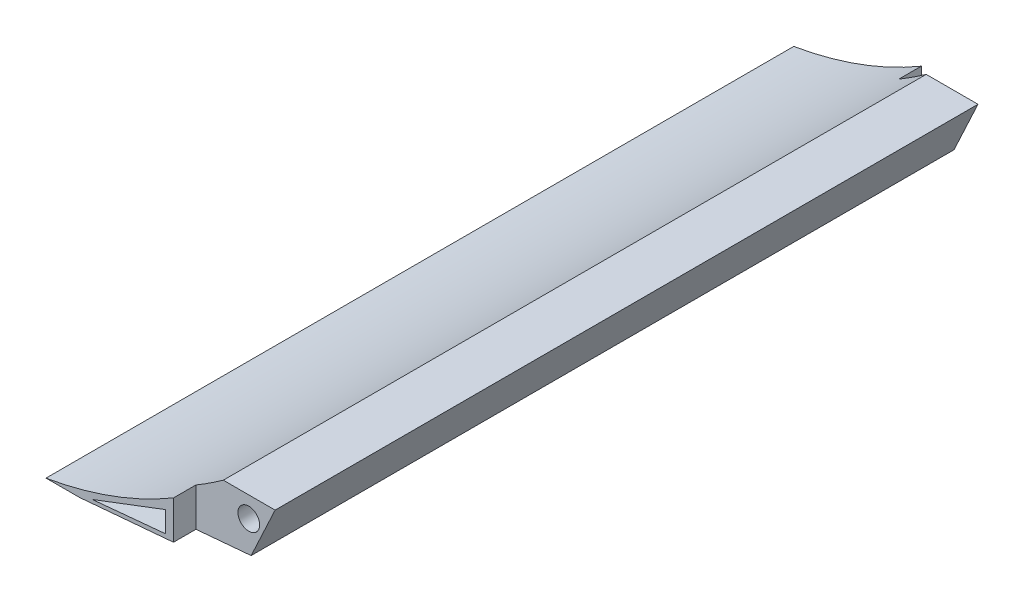
from build123d import *

# Parameters (mm, degrees)
EXTRUDE1_DEPTH     = 100
EXTRUDE5_DEPTH     = 3
SKETCH17_W         = 35
SKETCH17_H         = 13.283913387
CUT_EXTRUDE1_DEPTH = 100
SKETCH19_W         = 24.898249574
SKETCH19_H         = 2.5
CUT_EXTRUDE2_DEPTH = 100
CUT_EXTRUDE3_DEPTH = 98
SKETCH21_W         = 6.656858378
SKETCH21_H         = 5.544933951
CUT_EXTRUDE5_DEPTH = 3
SKETCH23_W         = 11.264163756
SKETCH23_H         = 3.071962193
CUT_EXTRUDE6_DEPTH = 3
SKETCH24_W         = 6.656858378
SKETCH24_H         = 5.544933951
CUT_EXTRUDE7_DEPTH = 3
SKETCH25_W         = 8.129030682
SKETCH25_H         = 5.409731787
CUT_EXTRUDE8_DEPTH = 3


with BuildPart() as part:
    # Sketch1 → Extrude1 (new body)
    with BuildSketch(Plane.XY):
        with BuildLine():
            Line((24.434543456, 1.743114855), (35, 24.400809531))
            ThreePointArc((35, 24.400809531), (20.23335986, 8.279731765), (0, 0))
            Line((0, 0), (4.510649495, 0))
            Line((4.510649495, 0), (24.434543456, 1.743114855))
        make_face()
    extrude(amount=EXTRUDE1_DEPTH)

    # Sketch10 → Extrude5 (cut)
    with BuildSketch(Plane.XY.offset(100)):
        Polygon((27.084425545, 11.426798952), (29.084425545, 11.066694717), (24.434543456, 1.743114855), (17.054195147, 3.071962193), align=None)
    extrude5 = extrude(amount=-EXTRUDE5_DEPTH, mode=Mode.SUBTRACT)

    # Mirror2: Extrude5 across plane
    add(extrude5.mirror(Plane.XY.offset(50)), mode=Mode.SUBTRACT)

    # Sketch16 → M2.5 Clearance Hole2 (revolve, cut)
    with BuildSketch(Plane(origin=(24.120076457, 5.864055695, 97), x_dir=(0, -1, 0), z_dir=(1, 0, 0))):
        Polygon((0, 0), (0, 16.871247898), (1.45, 16), (1.45, 0), align=None)
    m2_5_clearance_hole2 = revolve(axis=Axis((24.120076457, 5.864055695, 103.35), (0, 0, -1)), mode=Mode.SUBTRACT)

    # Mirror3: M2.5 Clearance Hole2 across plane
    add(m2_5_clearance_hole2.mirror(Plane.XY.offset(50)), mode=Mode.SUBTRACT)

    # Sketch17 → Cut-Extrude1 (cut)
    with BuildSketch(Plane.XY.offset(100)):
        with Locations((17.5, 17.758852838)):
            Rectangle(SKETCH17_W, SKETCH17_H)
    extrude(amount=-CUT_EXTRUDE1_DEPTH, mode=Mode.SUBTRACT)

    # Sketch19 → Cut-Extrude2 (cut)
    with BuildSketch(Plane.XY.offset(100)):
        with Locations((16.356484671, 9.866896144)):
            Rectangle(SKETCH19_W, SKETCH19_H)
    extrude(amount=-CUT_EXTRUDE2_DEPTH, mode=Mode.SUBTRACT)

    # Sketch20 → Cut-Extrude3 (cut)
    with BuildSketch(Plane.XY.offset(100)):
        Polygon((6.18702488, 0.620277991), (15.948528927, 4.330532923), (15.948528927, 1.543663509), align=None)
    extrude(amount=-CUT_EXTRUDE3_DEPTH, mode=Mode.SUBTRACT)

    # Sketch21 → Cut-Extrude5 (cut)
    with BuildSketch(Plane.XY.offset(100)):
        with Locations((20.382624336, 5.844429168)):
            Rectangle(SKETCH21_W, SKETCH21_H)
    extrude(amount=-CUT_EXTRUDE5_DEPTH, mode=Mode.SUBTRACT)

    # Sketch23 → Cut-Extrude6 (cut)
    with BuildSketch(Plane.XY.offset(100)):
        with Locations((22.686277025, 1.535981097)):
            Rectangle(SKETCH23_W, SKETCH23_H)
    extrude(amount=-CUT_EXTRUDE6_DEPTH, mode=Mode.SUBTRACT)

    # Sketch24 → Cut-Extrude7 (cut)
    with BuildSketch(Plane(origin=(0, 0, 0), x_dir=(-1, 0, 0), z_dir=(0, 0, -1))):
        with Locations((-20.382624336, 5.844429168)):
            Rectangle(SKETCH24_W, SKETCH24_H)
    extrude(amount=-CUT_EXTRUDE7_DEPTH, mode=Mode.SUBTRACT)

    # Sketch25 → Cut-Extrude8 (cut)
    with BuildSketch(Plane(origin=(0, 0, 0), x_dir=(-1, 0, 0), z_dir=(0, 0, -1))):
        with Locations((-21.118710488, 0.3670963)):
            Rectangle(SKETCH25_W, SKETCH25_H)
    extrude(amount=-CUT_EXTRUDE8_DEPTH, mode=Mode.SUBTRACT)


solid = part.part
